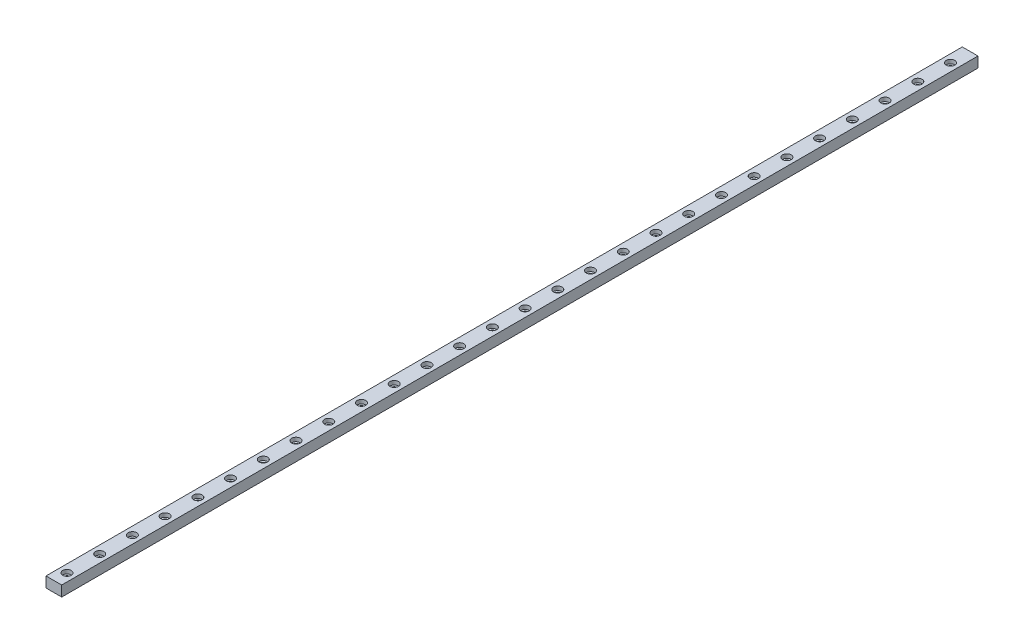
from build123d import *

# Parameters (mm, degrees)
SKETCH1_W                      = 12
SKETCH1_H                      = 8
BOSS_EXTRUDE1_DEPTH            = 700
CBORE_FOR_M3_SHCS1_D           = 3.4
CBORE_FOR_M3_SHCS1_CBORE_D     = 6.5
CBORE_FOR_M3_SHCS1_CBORE_DEPTH = 3


with BuildPart() as part:
    # Sketch1 → Boss-Extrude1 (new body)
    with BuildSketch(Plane.XY):
        with Locations((6, 4)):
            Rectangle(SKETCH1_W, SKETCH1_H)
    extrude(amount=BOSS_EXTRUDE1_DEPTH)

    # CBORE for M3 SHCS1 (through all)
    with Locations(Plane(origin=(0, 8, 0), x_dir=(1, 0, 0), z_dir=(0, 1, 0))):
        with Locations((6, -690), (6, -665), (6, -640), (6, -615), (6, -590), (6, -565), (6, -540), (6, -515), (6, -490), (6, -465), (6, -440), (6, -415), (6, -390), (6, -365), (6, -340), (6, -315), (6, -290), (6, -265), (6, -240), (6, -215), (6, -190), (6, -165), (6, -140), (6, -115), (6, -90), (6, -65), (6, -40), (6, -15)):
            CounterBoreHole(CBORE_FOR_M3_SHCS1_D / 2, CBORE_FOR_M3_SHCS1_CBORE_D / 2, CBORE_FOR_M3_SHCS1_CBORE_DEPTH)


solid = part.part
